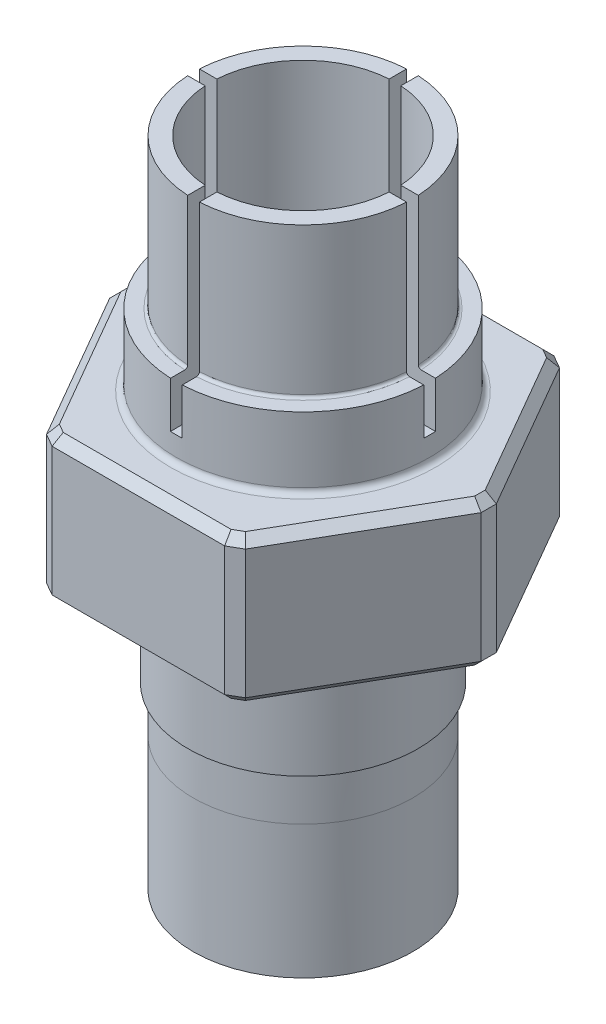
from build123d import *

# Parameters (mm, degrees)
SKETCH3_OUTSIDE_W  = 52.112
SKETCH3_OUTSIDE_H  = 52.112
HEX_2_DEPTH        = 58.094341399
CHAMFER1_SIZE      = 0.25
FILLET1_R          = 0.25
CUT_EXTRUDE1_DEPTH = 17
FILLET3_R          = 0.5
CUT_EXTRUDE2_DEPTH = 38.9
CIRPATTERN1_COUNT  = 6
CHAMFER2_SIZE      = 0.762
CHAMFER3_SIZE      = 0.508
CHAMFER3_SIZE2     = 0.87988181
CHAMFER4_SIZE      = 0.508


with BuildPart() as part:
    # Sketch1 → Revolve1 (revolve)
    with BuildSketch(Plane.XY, mode=Mode.PRIVATE) as revolve1_sk:
        Polygon((6.125, 0), (6.125, 45.094341399), (8, 45.094341399), (8, 57.094341399), (9.5123, 57.094341399), (9.5123, 44.094341399), (11, 44.094341399), (11, 37.9), (17.5, 37.9), (17.5, 25.2), (9.9875, 25.2), (9.9875, 16), (9.525, 16), (9.525, 0), align=None)
    revolve(revolve1_sk.sketch.rotate(Axis((0, 0, 0), (0, 1, 0)), 90), axis=Axis((0, 0, 0), (0, 1, 0)))  # turned: the seam where the file's is

    # Sketch3 outside → Hex 2 (cut, through all)
    with BuildSketch(Plane(origin=(0, 0, 0), x_dir=(1, 0, 0), z_dir=(0, 1, 0))):
        Rectangle(SKETCH3_OUTSIDE_W, SKETCH3_OUTSIDE_H)
        Polygon((8.248891971, 14.2875), (-8.248891971, 14.2875), (-16.497783942, 0), (-8.248891971, -14.2875), (8.248891971, -14.2875), (16.497783942, 0), align=None, mode=Mode.SUBTRACT)
    extrude(amount=HEX_2_DEPTH, mode=Mode.SUBTRACT)

    # Chamfer1
    chamfer1_edges = [part.edges().sort_by_distance(p)[0] for p in [
        (0, 45.094341399, 6.125),
    ]]
    chamfer(chamfer1_edges, length=CHAMFER1_SIZE)

    # Fillet1
    fillet1_edges = [part.edges().sort_by_distance(p)[0] for p in [
        (0, 44.094341399, 9.5123),
        (0, 45.094341399, 8),
        (0, 16, 9.525),
    ]]
    fillet(fillet1_edges, radius=FILLET1_R)

    # Sketch2 → Cut-Extrude1 (cut)
    with BuildSketch(Plane(origin=(0, 57.094341399, 0), x_dir=(1, 0, 0), z_dir=(0, 1, 0))):
        Polygon((11, 0.508), (0.508, 0.508), (0.508, 11), (-0.508, 11), (-0.508, 0.508), (-11, 0.508), (-11, -0.508), (-0.508, -0.508), (-0.508, -11), (0.508, -11), (0.508, -0.508), (11, -0.508), align=None)
    extrude(amount=-CUT_EXTRUDE1_DEPTH, mode=Mode.SUBTRACT)

    # Fillet3
    fillet3_edges = [part.edges().sort_by_distance(p)[0] for p in [
        (0, 25.2, 9.9875),
        (0, 37.9, 11),
    ]]
    fillet(fillet3_edges, radius=FILLET3_R)

    # Sketch6 → Cut-Extrude2 (cut, through all)
    with BuildSketch(Plane(origin=(0, 37.9, 0), x_dir=(1, 0, 0), z_dir=(0, 1, 0))):
        Polygon((-16.116783942, 0.659911358), (-16.116783942, -0.659911358), (-16.497783942, 0), align=None)
    cut_extrude2 = extrude(amount=-CUT_EXTRUDE2_DEPTH, mode=Mode.SUBTRACT)

    # CirPattern1: Cut-Extrude2 ×6 about axis
    cirpattern1_axis = Axis((0, 0, 0), (0, 1, 0))
    for i in range(1, CIRPATTERN1_COUNT):
        add(cut_extrude2.rotate(cirpattern1_axis, i * 360 / CIRPATTERN1_COUNT), mode=Mode.SUBTRACT)

    # Chamfer2
    chamfer2_edges = [part.edges().sort_by_distance(p)[0] for p in [
        (-12.373337957, 25.2, 7.14375),
        (-12.373337957, 37.9, -7.14375),
        (-16.116783942, 25.2, 0),
        (-16.116783942, 37.9, 0),
        (-12.373337957, 25.2, -7.14375),
        (0, 37.9, -14.2875),
        (-8.058391971, 25.2, -13.957544321),
        (-8.058391971, 37.9, -13.957544321),
        (0, 25.2, -14.2875),
        (12.373337957, 37.9, -7.14375),
        (8.058391971, 25.2, -13.957544321),
        (8.058391971, 37.9, -13.957544321),
        (12.373337957, 37.9, 7.14375),
        (12.373337957, 25.2, -7.14375),
        (16.116783942, 25.2, 0),
        (16.116783942, 37.9, 0),
        (12.373337957, 25.2, 7.14375),
        (0, 37.9, 14.2875),
        (8.058391971, 25.2, 13.957544321),
        (8.058391971, 37.9, 13.957544321),
        (0, 25.2, 14.2875),
        (-12.373337957, 37.9, 7.14375),
        (-8.058391971, 25.2, 13.957544321),
        (-8.058391971, 37.9, 13.957544321),
    ]]
    chamfer(chamfer2_edges, length=CHAMFER2_SIZE)

    # Chamfer3
    chamfer3_edges = [part.edges().sort_by_distance(p)[0] for p in [
        (0, 0, 9.525),
    ]]
    chamfer3_side = [part.faces().sort_by_distance(p)[0] for p in [
        (0, 7.875, 9.525),
    ]]
    chamfer(chamfer3_edges, length=CHAMFER3_SIZE, length2=CHAMFER3_SIZE2, reference=chamfer3_side[0])

    # Chamfer4
    chamfer4_edges = [part.edges().sort_by_distance(p)[0] for p in [
        (0, 0, 6.125),
    ]]
    chamfer(chamfer4_edges, length=CHAMFER4_SIZE)


solid = part.part
